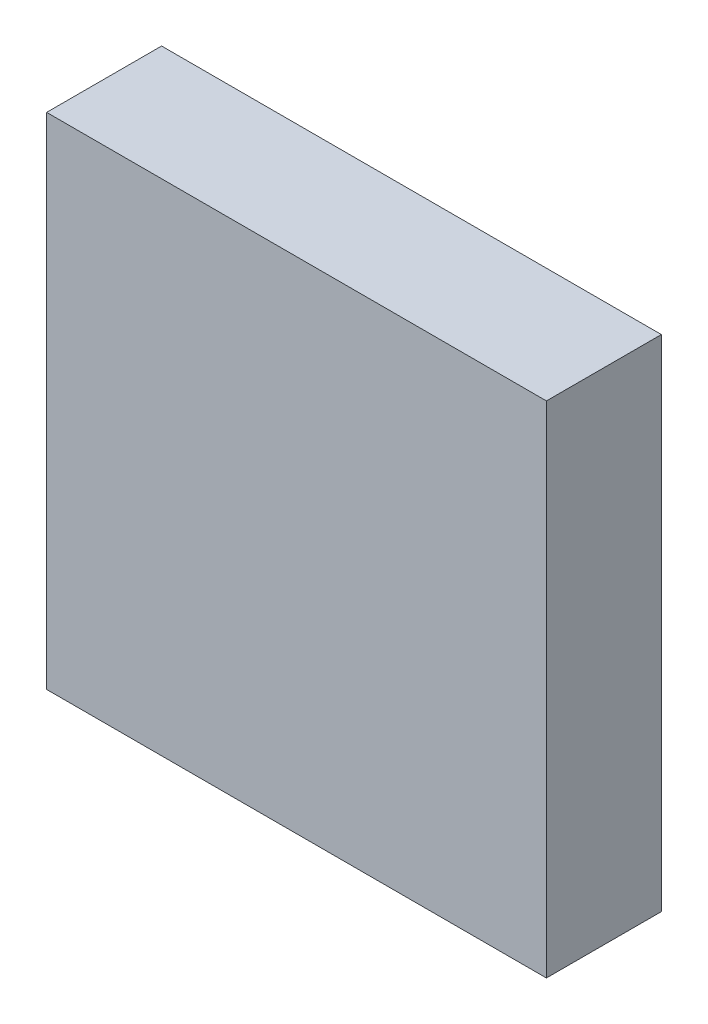
from build123d import *

# Parameters (mm, degrees)
SKETCH_1_W      = 10
SKETCH_1_H      = 10
EXTRUDE_1_DEPTH = 2.3


with BuildPart() as part:
    # 草图1 → 凸台-拉伸1 (new body)
    with BuildSketch(Plane.XY):
        with Locations((40.49917431, 24.625296734)):
            Rectangle(SKETCH_1_W, SKETCH_1_H)
    extrude(amount=EXTRUDE_1_DEPTH)


solid = part.part
